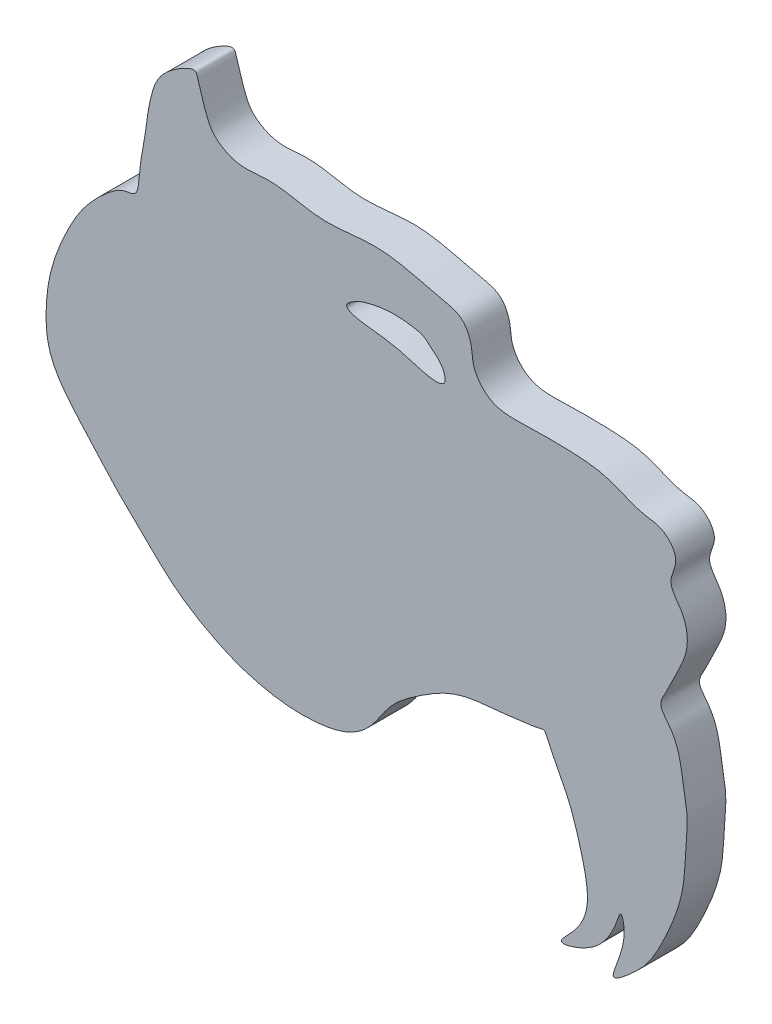
from build123d import *

# Parameters (mm, degrees)
BOSS_EXTRUDE1_DEPTH = 3
CUT_EXTRUDE1_DEPTH  = 3


with BuildPart() as part:
    # Sketch2 → Boss-Extrude1 (new body)
    with BuildSketch(Plane.XY):
        with BuildLine():
            add(Edge.make_bspline(
                [(-12.370045123, 24.134868517), (-12.274618502, 24.823355836), (-11.972495386, 26.145118302), (-11.738245767, 28.615681174), (-10.881027206, 31.036998872), (-8.165127034, 32.664204477), (-7.949904593, 32.051256929), (-7.292260028, 29.668130221), (-6.620509642, 28.578595027), (-4.620556995, 27.508599361), (-2.099348327, 28.183828392), (1.705391552, 26.90072201), (5.15064416, 27.72301771), (8.373347607, 27.288798285), (10.42480846, 26.683052926), (12.755274161, 26.250893924), (13.367528047, 24.715785809), (13.399755093, 23.031107097), (14.798007004, 21.254989763), (17.824870759, 21.365133724), (20.814663843, 21.401495225), (24.046893729, 21.145431874), (26.18366819, 19.919724831), (28.256159098, 19.836674282), (29.653598133, 18.185523383), (28.385553242, 16.385277525), (29.968162381, 14.784897011), (30.316507301, 12.308916474), (29.132853505, 10.427682508), (28.508223624, 8.903205577), (27.72629223, 7.774491309), (29.613078595, 5.887523065), (29.627305181, 3.730379816), (30.181294557, 1.131864941), (29.920522943, -0.809606114), (29.890627186, -4.026992837), (28.708437406, -7.071256747), (27.326280267, -9.77965947), (26.095720445, -11.156001536), (23.624276914, -13.244588806), (25.266103834, -10.128549945), (25.217113139, -8.342016822), (24.869649538, -7.620851517), (24.514423114, -8.965736518), (23.632223442, -10.423430368), (22.056591415, -11.75440246), (19.445764305, -12.465788374), (21.420534956, -10.811256176), (22.67363397, -8.568818653), (21.768668774, -4.730524414), (21.19274184, -2.971877663), (20.732321724, -1.85215609), (18.867852364, 1.701845792), (19.183996921, 1.618455542), (17.871063338, 1.351633908), (17.424360265, 1.346161375), (16.837230959, 1.2298725), (14.356211276, 0.948803558), (12.087463008, 0.840448269), (8.430982716, -1.476802717), (6.440552544, -3.103554842), (4.88660826, -6.536385156), (-0.54548691, -6.922440385), (-4.235005057, -6.200778047), (-6.875525457, -5.032721441), (-9.656395476, -3.414968671), (-12.38616075, -0.631910356), (-14.199046099, 1.033867965), (-16.474159316, 3.688602341), (-19.642731608, 6.99900536), (-19.80474644, 10.970962944), (-19.332508205, 13.915703776), (-17.875204012, 17.207983175), (-16.455234064, 19.408755553), (-13.642495238, 22.042234909), (-12.536714535, 21.300810603), (-12.472879074, 23.392938529), (-12.370045123, 24.134868517)],
                knots=[0, 0, 0, 0, 0.010467992, 0.019100119, 0.023532796, 0.029909122, 0.035688625, 0.044320753, 0.05100943, 0.054353768, 0.06524631, 0.079761601, 0.096885208, 0.103539903, 0.115516336, 0.121295839, 0.128250395, 0.131384771, 0.140250124, 0.149267611, 0.163263383, 0.174259501, 0.184589415, 0.189776274, 0.197007841, 0.203199592, 0.209601366, 0.218627341, 0.229252304, 0.232978492, 0.237622636, 0.242156451, 0.25858217, 0.261442555, 0.270760296, 0.280326297, 0.296854136, 0.306959329, 0.31253537, 0.320215383, 0.32876141, 0.336289054, 0.337573595, 0.341606821, 0.348053737, 0.353679653, 0.367810363, 0.375917641, 0.38434028, 0.395217334, 0.408547455, 0.416271774, 0.418769299, 0.431883437, 0.434978422, 0.446624163, 0.45003392, 0.467620268, 0.508042247, 0.528005895, 0.56248137, 0.6059477, 0.623742319, 0.638826806, 0.665958169, 0.709292149, 0.735428134, 0.764018517, 0.788836444, 0.822912302, 0.8519474, 0.887977048, 0.92167478, 0.942945594, 0.966295852, 0.988719448, 1, 1, 1, 1], degree=3))
        make_face()
    extrude(amount=BOSS_EXTRUDE1_DEPTH)

    # Sketch3 → Cut-Extrude1 (cut)
    with BuildSketch(Plane(origin=(0, 0, 0), x_dir=(-1, 0, 0), z_dir=(0, 0, -1))):
        with BuildLine():
            add(Edge.make_bspline(
                [(-10.19992102, 22.881764522), (-10.079824125, 22.985170025), (-9.782119194, 23.294561029), (-9.248195705, 23.52079003), (-8.918605924, 23.572337163), (-7.257136734, 23.830892879), (-5.640113601, 23.564305248), (-4.412324296, 23.184847044), (-2.915621154, 22.167143879), (-6.1411427, 21.741390474), (-7.774452105, 21.619561615), (-11.641237853, 20.16616833), (-11.089291966, 22.190645106), (-10.445044918, 22.69324014), (-10.227809664, 22.857751918), (-10.19992102, 22.881764522)],
                knots=[0, 0, 0, 0, 0.03483308, 0.04423595, 0.094028695, 0.185357299, 0.316426829, 0.372439399, 0.425577589, 0.551556527, 0.678366097, 0.876954064, 0.919111368, 0.991911137, 1, 1, 1, 1], degree=3))
        make_face()
    extrude(amount=-CUT_EXTRUDE1_DEPTH, mode=Mode.SUBTRACT)


solid = part.part
